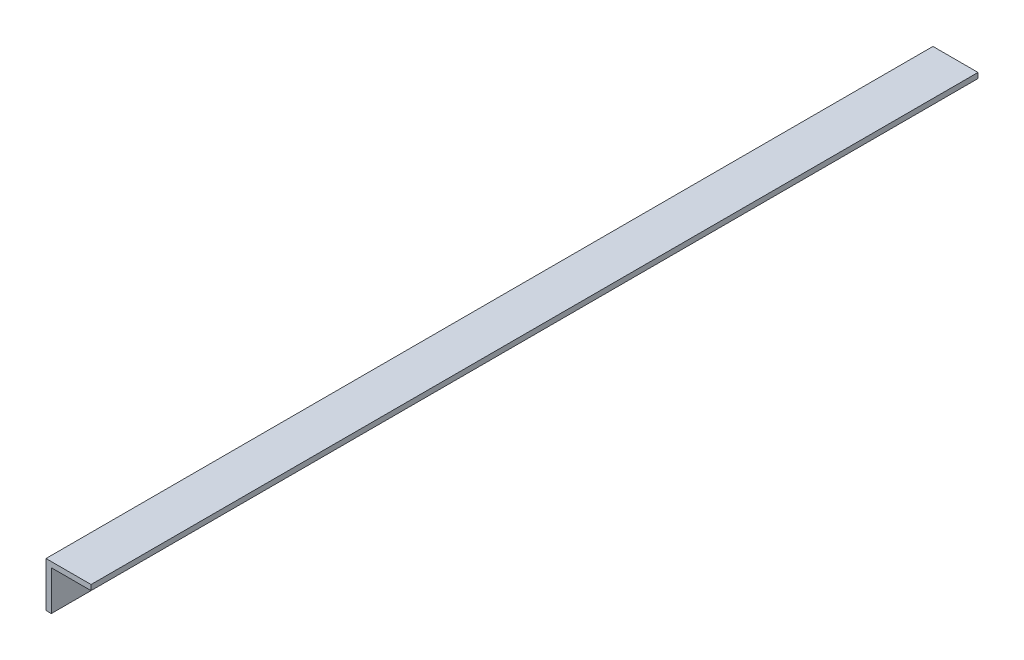
from build123d import *

# Parameters (mm, degrees)
BOSS_EXTRUDE1_DEPTH = 500


with BuildPart() as part:
    # Sketch1 → Boss-Extrude1 (new body)
    with BuildSketch(Plane.XY):
        Polygon((0, 0), (0, -25.4), (3, -25.4), (3, -3), (25.4, -3), (25.4, 0), align=None)
    extrude(amount=BOSS_EXTRUDE1_DEPTH)


solid = part.part
